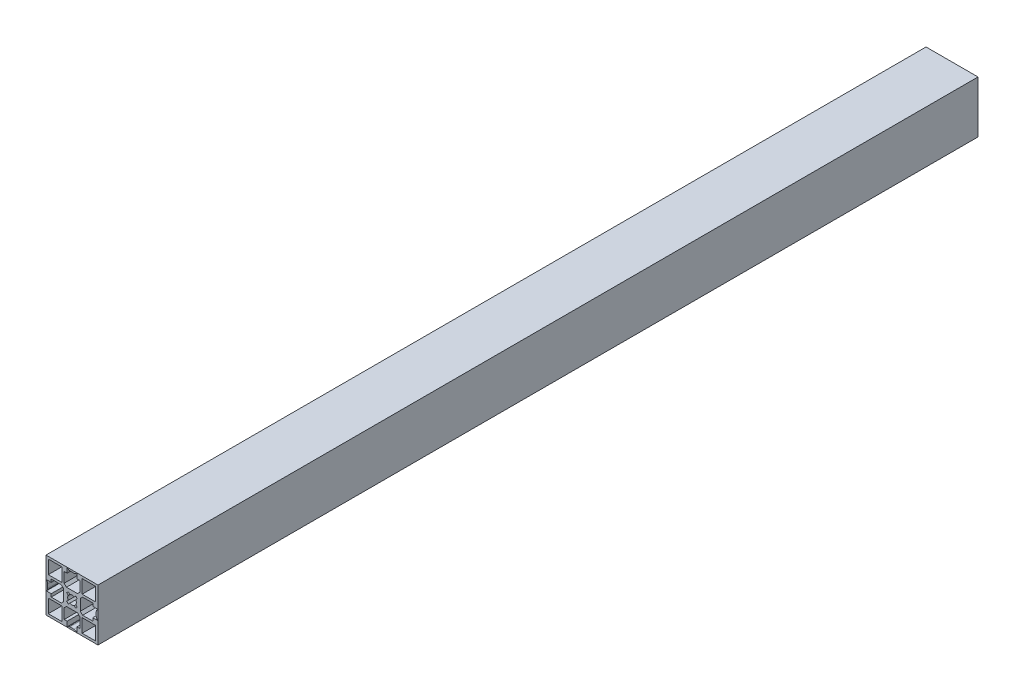
from build123d import *

# Parameters (mm, degrees)
SKETCH1_W           = 11.699975178
SKETCH1_H           = 11.699996949
SKETCH1_W_2         = 11.699990436
SKETCH1_H_2         = 11.699981689
SKETCH1_W_3         = 11.699981689
SKETCH1_H_3         = 11.699990436
SKETCH1_W_4         = 11.699990437
SKETCH1_H_4         = 11.699975177
BOSS_EXTRUDE1_DEPTH = 762


with BuildPart() as part:
    # Sketch1 → Boss-Extrude1 (new body)
    with BuildSketch(Plane.XY):
        Polygon((-22.499484948, -22.500701346), (22.500514502, -22.500701895), (22.500515052, 22.499297556), (-22.499484399, 22.499298105), align=None)
        with Locations((-14.649542346, -14.650709384)):
            Rectangle(SKETCH1_W, SKETCH1_H, mode=Mode.SUBTRACT)
        with Locations((14.65050626, -14.650767962)):
            Rectangle(SKETCH1_W_2, SKETCH1_H_2, mode=Mode.SUBTRACT)
        with Locations((14.650561583, 14.6492839)):
            Rectangle(SKETCH1_W_3, SKETCH1_H_3, mode=Mode.SUBTRACT)
        with Locations((-14.64949028, 14.649335967)):
            Rectangle(SKETCH1_W_4, SKETCH1_H_4, mode=Mode.SUBTRACT)
        with BuildLine():
            Line((-22.199510799, -3.950696126), (-21.731790056, -3.48300681))
            ThreePointArc((-21.731790056, -3.48300681), (-21.189814855, -2.671927844), (-20.999497617, -1.71518046))
            Line((-20.999497617, -1.71518046), (-20.999497617, 1.713721031))
            ThreePointArc((-20.999497617, 1.713721031), (-21.189799286, 2.670430863), (-21.731732544, 3.481489907))
            Line((-21.731732544, 3.481489907), (-22.199510888, 3.949267256))
            Line((-22.199510888, 3.949267256), (-22.199510888, 4.249285566))
            Line((-22.199510888, 4.249285566), (-17.999497356, 4.249285704))
            Line((-17.999497356, 4.249285704), (-17.999497356, 6.79927354))
            Line((-17.999497356, 6.79927354), (-9.199509947, 6.799273828))
            Line((-9.199509947, 6.799273828), (-7.199509956, 4.799274012))
            Line((-7.199509956, 4.799274012), (-7.199509641, -4.800732197))
            Line((-7.199509641, -4.800732197), (-9.199509449, -6.800732179))
            Line((-9.199509449, -6.800732179), (-17.99949762, -6.800732468))
            Line((-17.99949762, -6.800732468), (-17.99949762, -4.250714253))
            Line((-17.99949762, -4.250714253), (-22.199510799, -4.250714391))
            Line((-22.199510799, -4.250714391), (-22.199510799, -3.950696126))
        make_face(mode=Mode.SUBTRACT)
        with BuildLine():
            Line((-6.799479919, -18.000719999), (-6.799480207, -9.200732353))
            Line((-6.799480207, -9.200732353), (-4.799480391, -7.200732362))
            Line((-4.799480391, -7.200732362), (4.800525817, -7.200732047))
            Line((4.800525817, -7.200732047), (6.8005258, -9.200731855))
            Line((6.8005258, -9.200731855), (6.800526088, -18.000720263))
            Line((6.800526088, -18.000720263), (4.250507877, -18.000720263))
            Line((4.250507877, -18.000720263), (4.250508015, -22.200733153))
            Line((4.250508015, -22.200733153), (3.950489751, -22.200733153))
            Line((3.950489751, -22.200733153), (3.482800434, -21.73301241))
            ThreePointArc((3.482800434, -21.73301241), (2.671721468, -21.191037209), (1.714974084, -21.000719971))
            Line((1.714974084, -21.000719971), (-1.713927407, -21.000719971))
            ThreePointArc((-1.713927407, -21.000719971), (-2.670637239, -21.19102164), (-3.481696283, -21.732954898))
            Line((-3.481696283, -21.732954898), (-3.949473632, -22.200733242))
            Line((-3.949473632, -22.200733242), (-4.249491942, -22.200733242))
            Line((-4.249491942, -22.200733242), (-4.24949208, -18.000719999))
            Line((-4.24949208, -18.000719999), (-6.799479919, -18.000719999))
        make_face(mode=Mode.SUBTRACT)
        with BuildLine():
            Line((7.200519471, -4.800702751), (7.200519156, 4.799303458))
            Line((7.200519156, 4.799303458), (9.200518964, 6.79930344))
            Line((9.200518964, 6.79930344), (18.000507424, 6.799303729))
            Line((18.000507424, 6.799303729), (18.000507424, 4.249285514))
            Line((18.000507424, 4.249285514), (22.200520261, 4.249285652))
            Line((22.200520261, 4.249285652), (22.200520261, 3.949267391))
            Line((22.200520261, 3.949267391), (21.732799519, 3.481578075))
            ThreePointArc((21.732799519, 3.481578075), (21.190824318, 2.670499108), (21.000507079, 1.713751724))
            Line((21.000507079, 1.713751724), (21.000507079, -1.715149766))
            ThreePointArc((21.000507079, -1.715149766), (21.190808749, -2.671859599), (21.732742007, -3.482918643))
            Line((21.732742007, -3.482918643), (22.200520351, -3.950695992))
            Line((22.200520351, -3.950695992), (22.200520351, -4.250714302))
            Line((22.200520351, -4.250714302), (18.000507108, -4.25071444))
            Line((18.000507108, -4.25071444), (18.000507108, -6.800702279))
            Line((18.000507108, -6.800702279), (9.200519462, -6.800702567))
            Line((9.200519462, -6.800702567), (7.200519471, -4.800702751))
        make_face(mode=Mode.SUBTRACT)
        with BuildLine():
            Line((-4.799479817, 7.199303635), (-6.799479854, 9.199304042))
            Line((-6.799479854, 9.199304042), (-6.799479244, 17.999291576))
            Line((-6.799479244, 17.999291576), (-4.249491247, 17.999291576))
            Line((-4.249491247, 17.999291576), (-4.249490956, 22.199304807))
            Line((-4.249490956, 22.199304807), (-3.949472548, 22.199304807))
            Line((-3.949472548, 22.199304807), (-3.481695222, 21.73152644))
            ThreePointArc((-3.481695222, 21.73152644), (-2.670636178, 21.189593132), (-1.713926324, 20.999291428))
            Line((-1.713926324, 20.999291428), (1.714975167, 20.999291428))
            ThreePointArc((1.714975167, 20.999291428), (2.671722509, 21.189608628), (3.482801459, 21.731583767))
            Line((3.482801459, 21.731583767), (3.950490798, 22.199304487))
            Line((3.950490798, 22.199304487), (4.250509108, 22.199304487))
            Line((4.250509108, 22.199304487), (4.250508817, 17.999291575))
            Line((4.250508817, 17.999291575), (6.800527063, 17.999291575))
            Line((6.800527063, 17.999291575), (6.800526453, 9.199302988))
            Line((6.800526453, 9.199302988), (4.800526064, 7.199302969))
            Line((4.800526064, 7.199302969), (-4.799479817, 7.199303635))
        make_face(mode=Mode.SUBTRACT)
        with BuildLine():
            Line((-4.595670829, -3.182694885), (-3.26221457, -1.849238626))
            ThreePointArc((-3.26221457, -1.849238626), (-3.749476751, -0.00071437), (-3.26221457, 1.847809887))
            Line((-3.26221457, 1.847809887), (-4.595670829, 3.181266146))
            Line((-4.595670829, 3.181266146), (-3.181457266, 4.595479708))
            Line((-3.181457266, 4.595479708), (-1.848001007, 3.262023449))
            ThreePointArc((-1.848001007, 3.262023449), (0.000523249, 3.74928563), (1.849047505, 3.262023449))
            Line((1.849047505, 3.262023449), (3.182503764, 4.595479708))
            Line((3.182503764, 4.595479708), (4.596717327, 3.181266146))
            Line((4.596717327, 3.181266146), (3.263261068, 1.847809887))
            ThreePointArc((3.263261068, 1.847809887), (3.750523249, -0.00071437), (3.263261068, -1.849238626))
            Line((3.263261068, -1.849238626), (4.596717327, -3.182694885))
            Line((4.596717327, -3.182694885), (3.182503764, -4.596908447))
            Line((3.182503764, -4.596908447), (1.849047505, -3.263452188))
            ThreePointArc((1.849047505, -3.263452188), (0.000523249, -3.75071437), (-1.848001007, -3.263452188))
            Line((-1.848001007, -3.263452188), (-3.181457266, -4.596908447))
            Line((-3.181457266, -4.596908447), (-4.595670829, -3.182694885))
        make_face(mode=Mode.SUBTRACT)
    extrude(amount=BOSS_EXTRUDE1_DEPTH)


solid = part.part
